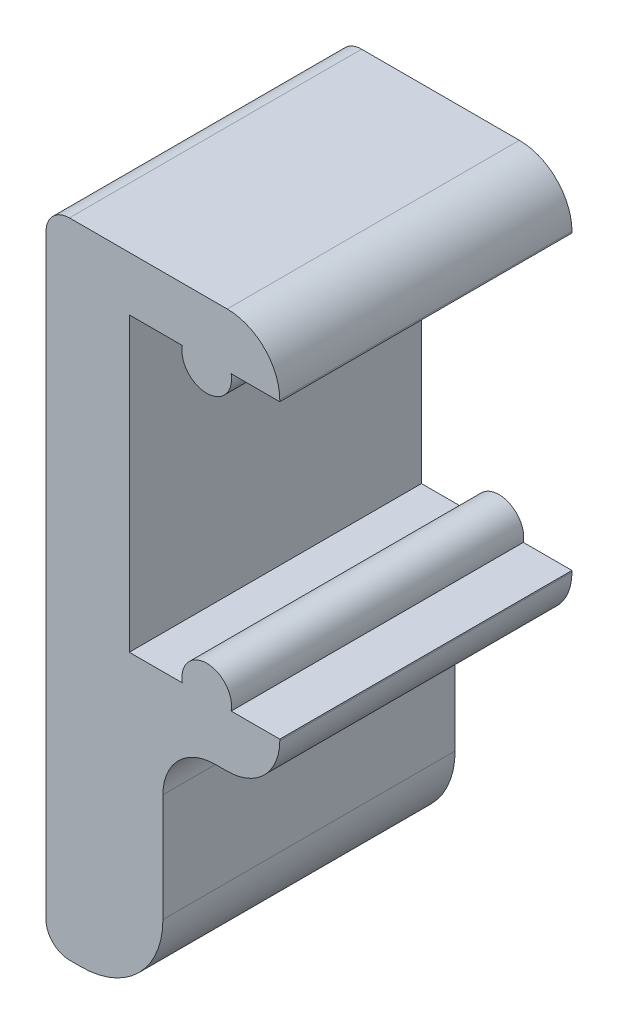
from build123d import *

# Parameters (mm, degrees)
BOSS_EXTRUDE1_DEPTH = 10


with BuildPart() as part:
    # Sketch4 → Boss-Extrude1 (new body)
    with BuildSketch(Plane.XY):
        with BuildLine():
            ThreePointArc((0.8, 0), (0.234314575, 0.234314575), (0, 0.8))
            Line((0, 0.8), (0, 21.2))
            ThreePointArc((0, 21.2), (0.234314575, 21.765685425), (0.8, 22))
            Line((0.8, 22), (6.2, 22))
            ThreePointArc((6.2, 22), (7.472792206, 21.472792206), (8, 20.2))
            Line((8, 20.2), (8, 20.15))
            Line((8, 20.15), (2.85, 20.15))
            Line((2.85, 20.15), (2.85, 10.15))
            Line((2.85, 10.15), (8, 10.15))
            Line((8, 10.15), (8, 10.1))
            ThreePointArc((8, 10.1), (7.472792206, 8.827207794), (6.2, 8.3))
            Line((6.2, 8.3), (5.8, 8.3))
            ThreePointArc((5.8, 8.3), (4.527207794, 7.772792206), (4, 6.5))
            Line((4, 6.5), (4, 2.8))
            ThreePointArc((4, 2.8), (3.179898987, 0.820101013), (1.2, 0))
            Line((1.2, 0), (0.8, 0))
        make_face()
        with BuildLine():
            ThreePointArc((4.663339973, 20.15), (5.5, 19.15), (6.336660027, 20.15))
            Line((6.336660027, 20.15), (4.663339973, 20.15))
        make_face()
        with BuildLine():
            Line((4.663339973, 10.15), (6.336660027, 10.15))
            ThreePointArc((6.336660027, 10.15), (5.5, 11.15), (4.663339973, 10.15))
        make_face()
    extrude(amount=BOSS_EXTRUDE1_DEPTH)


solid = part.part
